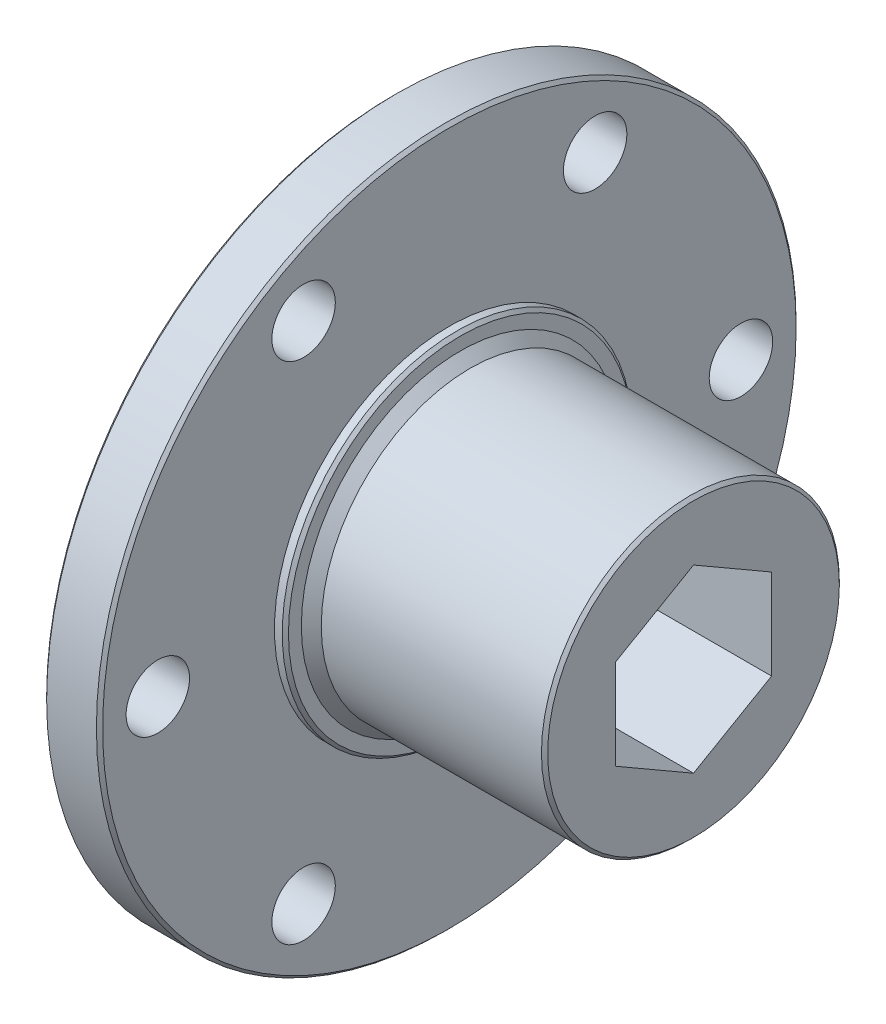
from build123d import *

# Parameters (mm, degrees)
SKETCH1_W                      = 4.572
SKETCH1_H                      = 28.575
SKETCH2_R                      = 14.2875
BOSS_EXTRUDE1_DEPTH            = 0.889
SKETCH3_R                      = 12.9794
BOSS_EXTRUDE2_DEPTH            = 0.8128
BOSS_EXTRUDE2_TAPER            = 45
SKETCH4_R                      = 12.1666
BOSS_EXTRUDE3_DEPTH            = 18.2372
SKETCH5_R                      = 14.2875
BOSS_EXTRUDE4_DEPTH            = 0.889
CUT_EXTRUDE1_DEPTH             = 26.4
F_6_0_204_DIAMETER_HOLE1_D     = 5.1816
F_6_0_204_DIAMETER_HOLE1_DEPTH = 24.511
CHAMFER1_SIZE                  = 0.254


with BuildPart() as part:
    # Sketch1 → Revolve1 (revolve)
    with BuildSketch(Plane(origin=(0, 0, 0), x_dir=(-1, 0, 0), z_dir=(0, 0, -1))):
        with Locations((16.210066246, 14.2875)):
            Rectangle(SKETCH1_W, SKETCH1_H)
    revolve(axis=Axis((-13.924066246, 0, 0), (-1, 0, 0)))

    # Sketch2 → Boss-Extrude1 (add)
    with BuildSketch(Plane(origin=(-13.924066246, 0, 0), x_dir=(0, 0, -1), z_dir=(1, 0, 0))):
        Circle(SKETCH2_R)
    extrude(amount=BOSS_EXTRUDE1_DEPTH)

    # Sketch3 → Boss-Extrude2 (add)
    with BuildSketch(Plane(origin=(-13.035066246, 0, 0), x_dir=(0, 0, -1), z_dir=(1, 0, 0))):
        Circle(SKETCH3_R)
    extrude(amount=BOSS_EXTRUDE2_DEPTH, taper=BOSS_EXTRUDE2_TAPER)

    # Sketch4 → Boss-Extrude3 (add)
    with BuildSketch(Plane(origin=(-12.222266246, 0, 0), x_dir=(0, 0, -1), z_dir=(1, 0, 0))):
        Circle(SKETCH4_R)
    extrude(amount=BOSS_EXTRUDE3_DEPTH)

    # Sketch5 → Boss-Extrude4 (add)
    with BuildSketch(Plane.ZY.offset(18.496066246)):
        Circle(SKETCH5_R)
    extrude(amount=BOSS_EXTRUDE4_DEPTH)

    # Sketch6 → Cut-Extrude1 (cut, through all)
    with BuildSketch(Plane.ZY.offset(19.385066246)):
        Polygon((0, 7.361657812), (-6.3754, 3.680818906), (-6.3754, -3.680858906), (0, -7.361697812), (6.3754, -3.680858906), (6.3754, 3.680818906), align=None)
    extrude(amount=-CUT_EXTRUDE1_DEPTH, mode=Mode.SUBTRACT)

    # #6 (0.204) Diameter Hole1
    with Locations(Plane.ZY.offset(18.496066246)):
        with Locations((11.90625, 20.622229928), (-23.8125, 0), (11.90625, -20.622229928), (-11.90625, -20.622229928), (-11.90625, 20.622229928), (23.8125, 0)):
            Hole(F_6_0_204_DIAMETER_HOLE1_D / 2, depth=F_6_0_204_DIAMETER_HOLE1_DEPTH)

    # Chamfer1
    chamfer1_edges = [part.edges().sort_by_distance(p)[0] for p in [
        (6.014933754, 0, 12.1666),
        (-19.385066246, 0, -14.2875),
        (-18.496066246, -28.575, 0),
        (-13.924066246, -28.575, 0),
        (-13.035066246, 0, 14.2875),
    ]]
    chamfer(chamfer1_edges, length=CHAMFER1_SIZE)


solid = part.part
